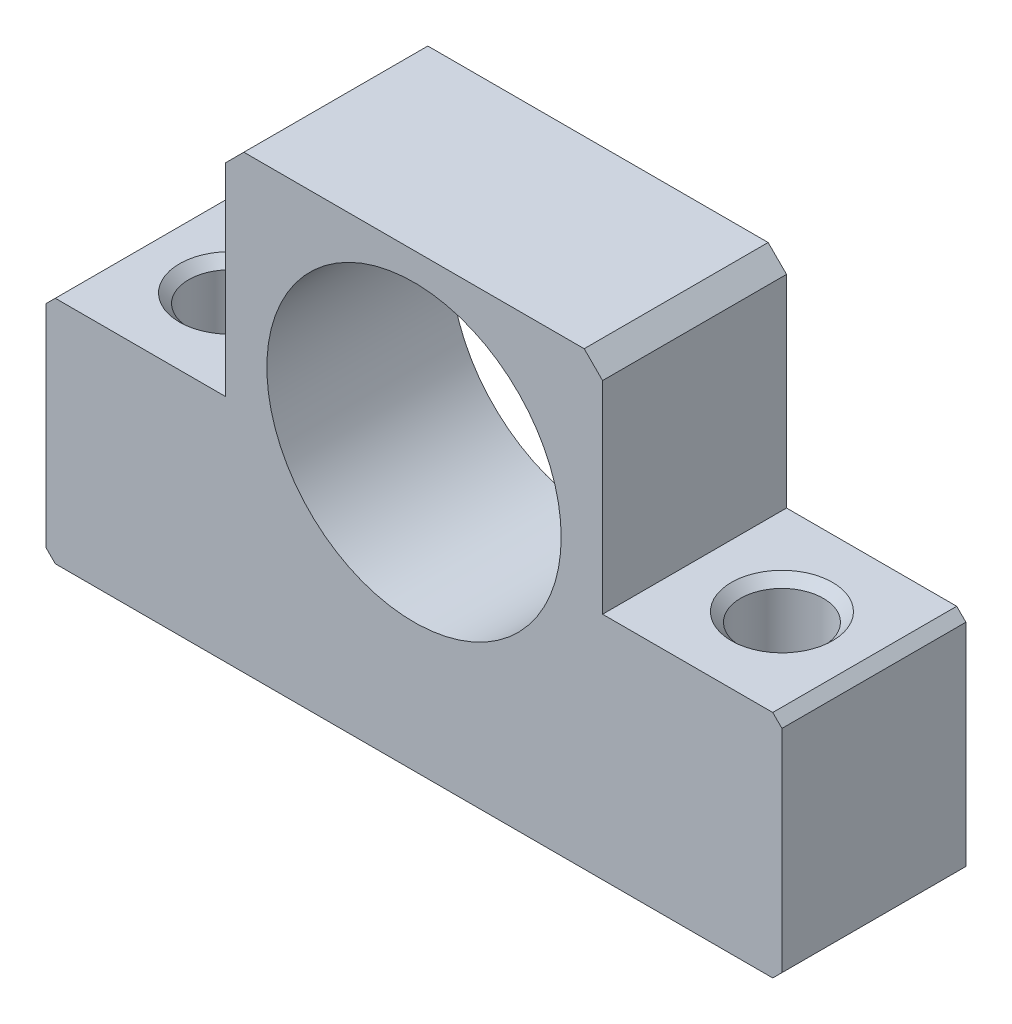
from build123d import *

# Parameters (mm, degrees)
SKETCH1_R           = 16
BOSS_EXTRUDE1_DEPTH = 20


with BuildPart() as part:
    # Sketch1 → Boss-Extrude1 (new body)
    with BuildSketch(Plane.XY):
        Polygon((-40, -29), (-39, -30), (39, -30), (40, -29), (40, -6), (39, -5), (20.5, -5), (20.5, 17), (18.5, 19), (-18.5, 19), (-20.5, 17), (-20.5, -5), (-39, -5), (-40, -6), align=None)
        Circle(SKETCH1_R, mode=Mode.SUBTRACT)
    extrude(amount=-BOSS_EXTRUDE1_DEPTH)

    # Sketch2 → Cut-Revolve1 (revolve, cut)
    with BuildSketch(Plane.XY.offset(-10)):
        Polygon((30, -5), (35.5, -5), (34.5, -6), (34.5, -29), (35.5, -30), (30, -30), align=None)
    revolve(axis=Axis((30, -30, -10), (0, 1, 0)), mode=Mode.SUBTRACT)

    # Sketch3 → Cut-Revolve2 (revolve, cut)
    with BuildSketch(Plane.XY.offset(-10)):
        Polygon((-30, -5), (-24.5, -5), (-25.5, -6), (-25.5, -29), (-24.5, -30), (-30, -30), align=None)
    revolve(axis=Axis((-30, -30, -10), (0, 1, 0)), mode=Mode.SUBTRACT)


solid = part.part
